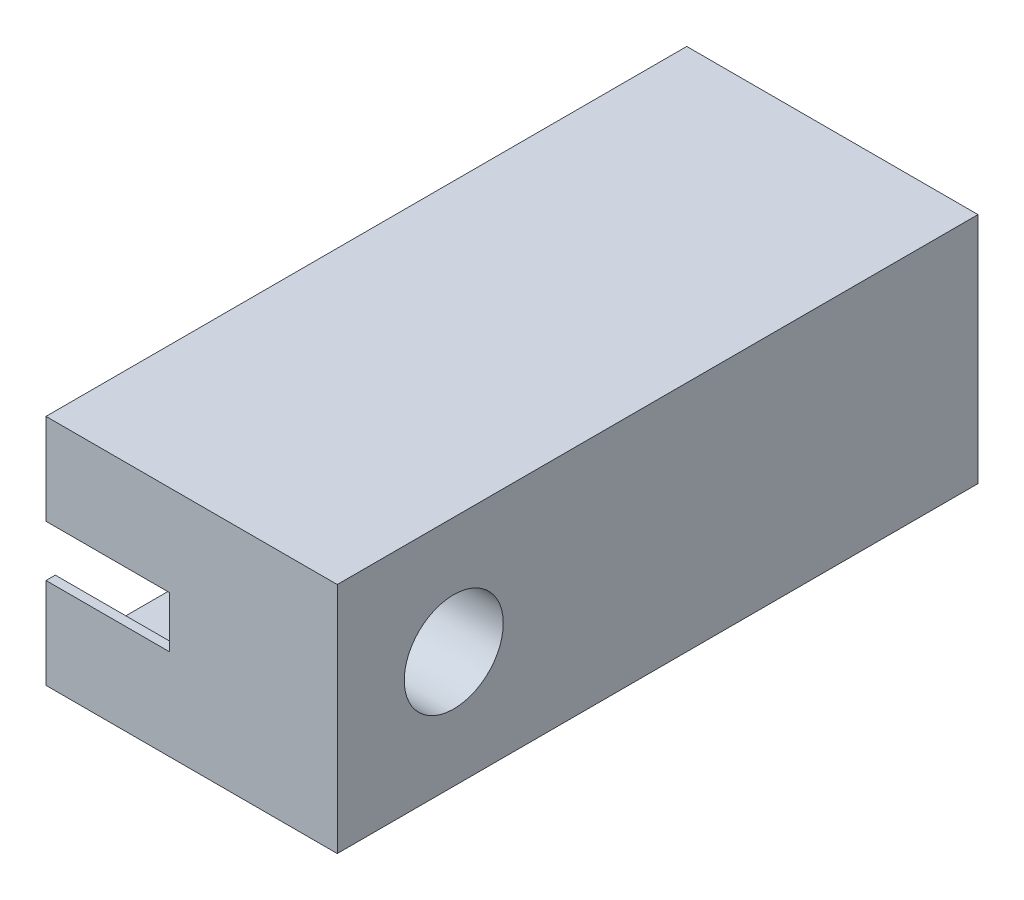
from build123d import *

# Parameters (mm, degrees)
SKETCH1_W           = 69.85
SKETCH1_H           = 25.4
SKETCH1_R           = 5.3975
BOSS_EXTRUDE1_DEPTH = 31.75
SKETCH2_W           = 71.374
SKETCH2_H           = 20.955
CUT_EXTRUDE1_DEPTH  = 22.86
SKETCH2_3_W         = 5.08
SKETCH2_3_H         = 5.588
CUT_EXTRUDE2_DEPTH  = 13.462
SKETCH3_R           = 1.5875
CUT_EXTRUDE3_DEPTH  = 63.848962601
BOSS_EXTRUDE2_START = -2.54
SKETCH8_R           = 1.5875
BOSS_EXTRUDE2_DEPTH = 2.54


with BuildPart() as part:
    # Sketch1 → Boss-Extrude1 (new body)
    with BuildSketch(Plane(origin=(0, 0, 0), x_dir=(0, 0, -1), z_dir=(1, 0, 0))):
        with Locations((22.225, 0)):
            Rectangle(SKETCH1_W, SKETCH1_H)
        Circle(SKETCH1_R, mode=Mode.SUBTRACT)
    extrude(amount=BOSS_EXTRUDE1_DEPTH)

    # Sketch2 → Cut-Extrude1 (cut)
    with BuildSketch(Plane.ZY):
        with Locations((-24.003, 0)):
            Rectangle(SKETCH2_W, SKETCH2_H)
    extrude(amount=-CUT_EXTRUDE1_DEPTH, mode=Mode.SUBTRACT)

    # Sketch2_3 → Cut-Extrude2 (cut)
    with BuildSketch(Plane.ZY):
        with Locations((14.224, 0)):
            Rectangle(SKETCH2_3_W, SKETCH2_3_H)
    extrude(amount=-CUT_EXTRUDE2_DEPTH, mode=Mode.SUBTRACT)

    # Sketch3 → Cut-Extrude3 (cut, through all)
    with BuildSketch(Plane.ZY.offset(-22.86)):
        with Locations((-53.975, 6.35)):
            Circle(SKETCH3_R)
        with Locations((-53.975, -6.35)):
            Circle(SKETCH3_R)
    extrude(amount=-CUT_EXTRUDE3_DEPTH, mode=Mode.SUBTRACT)

    # Sketch8 → Boss-Extrude2 (add)
    with BuildSketch(Plane(origin=(31.75, 0, 0), x_dir=(0, 0, -1), z_dir=(1, 0, 0)).offset(BOSS_EXTRUDE2_START)):
        with Locations((53.975, -6.35)):
            Circle(SKETCH8_R)
        with Locations((53.975, 6.35)):
            Circle(SKETCH8_R)
    extrude(amount=BOSS_EXTRUDE2_DEPTH)


solid = part.part
